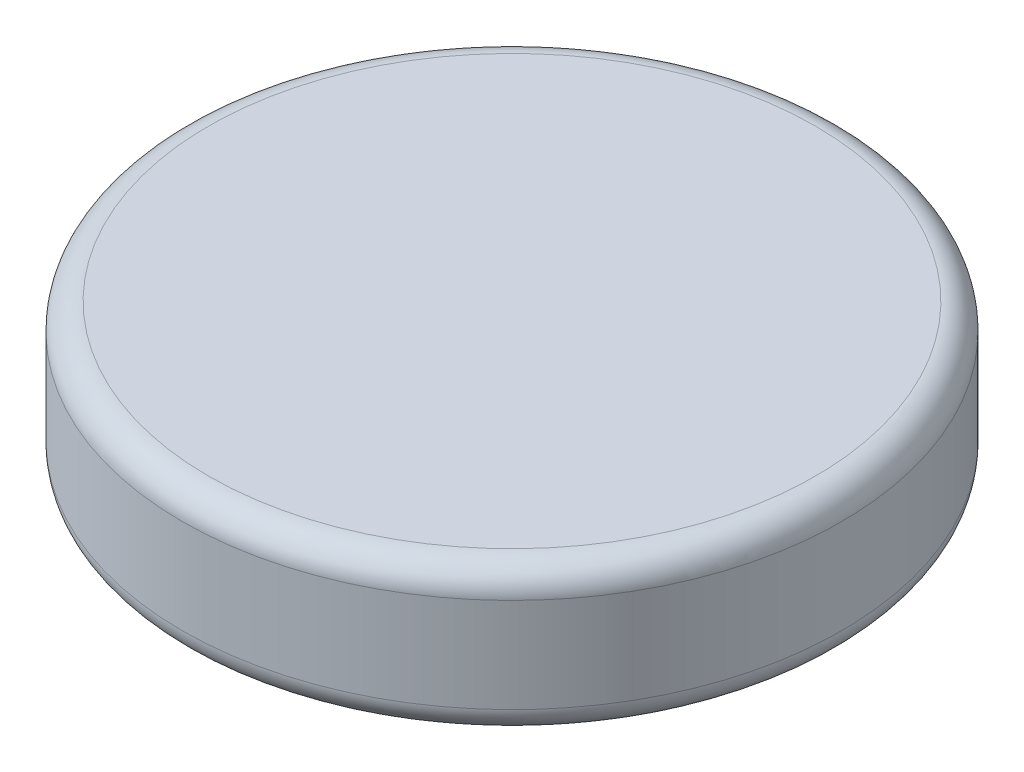
from build123d import *

# Parameters (mm, degrees)
SKETCH1_R           = 15.9385
BOSS_EXTRUDE1_DEPTH = 7.112
FILLET1_R           = 1.27


with BuildPart() as part:
    # Sketch1 → Boss-Extrude1 (new body)
    with BuildSketch(Plane(origin=(0, 0, 0), x_dir=(1, 0, 0), z_dir=(0, 1, 0))):
        Circle(SKETCH1_R)
    extrude(amount=BOSS_EXTRUDE1_DEPTH)

    # Fillet1
    fillet1_edges = [part.edges().sort_by_distance(p)[0] for p in [
        (-15.9385, 0, 0),
        (-15.9385, 7.112, 0),
    ]]
    fillet(fillet1_edges, radius=FILLET1_R)


solid = part.part
